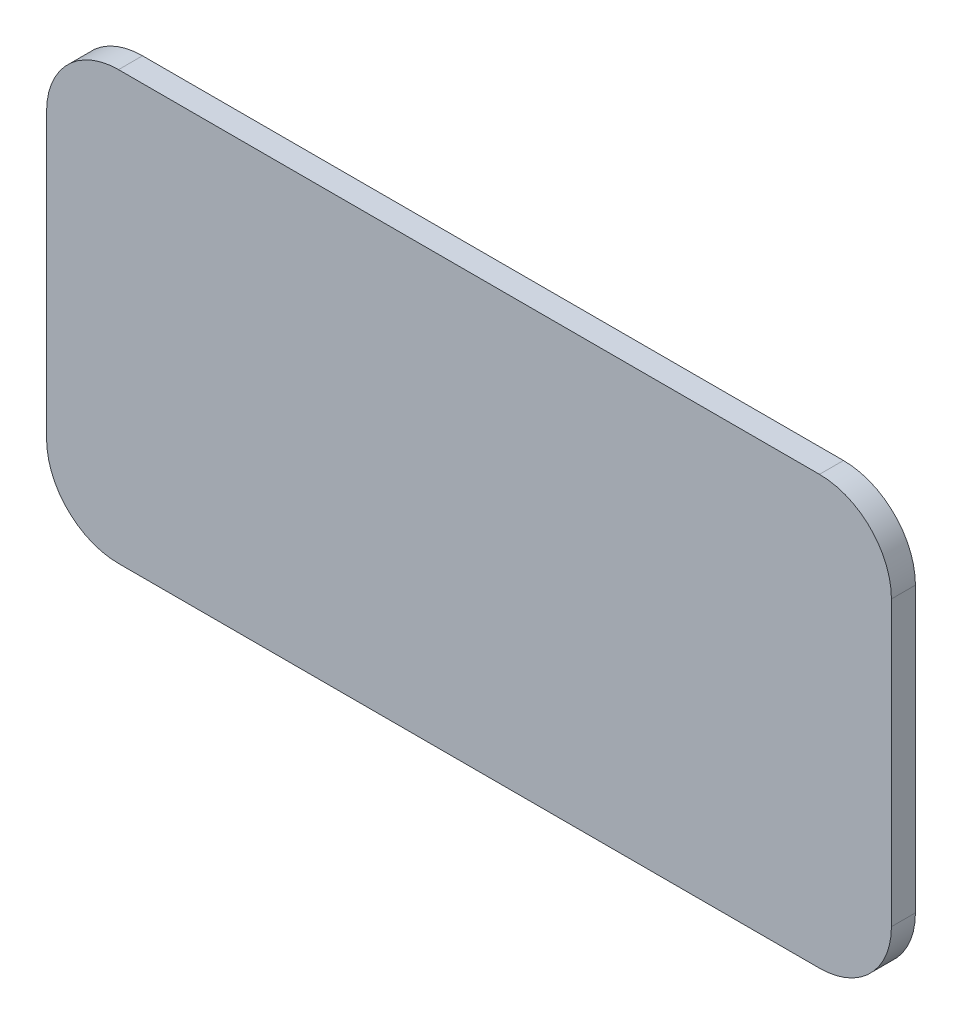
from build123d import *

# Parameters (mm, degrees)
BOSS_EXTRUDE1_DEPTH = 6


with BuildPart() as part:
    # Sketch1 → Boss-Extrude1 (new body)
    with BuildSketch(Plane.XY):
        with BuildLine():
            Line((-238.35, -11), (-62.991811867, -11))
            ThreePointArc((-62.991811867, -11), (-50.263889805, -5.727922061), (-44.991811867, 7))
            Line((-44.991811867, 7), (-44.991811867, 78))
            ThreePointArc((-44.991811867, 78), (-50.263889805, 90.727922061), (-62.991811867, 96))
            Line((-62.991811867, 96), (-238.35, 96))
            ThreePointArc((-238.35, 96), (-251.077922061, 90.727922061), (-256.35, 78))
            Line((-256.35, 78), (-256.35, 7))
            ThreePointArc((-256.35, 7), (-251.077922061, -5.727922061), (-238.35, -11))
        make_face()
    extrude(amount=BOSS_EXTRUDE1_DEPTH)


solid = part.part
